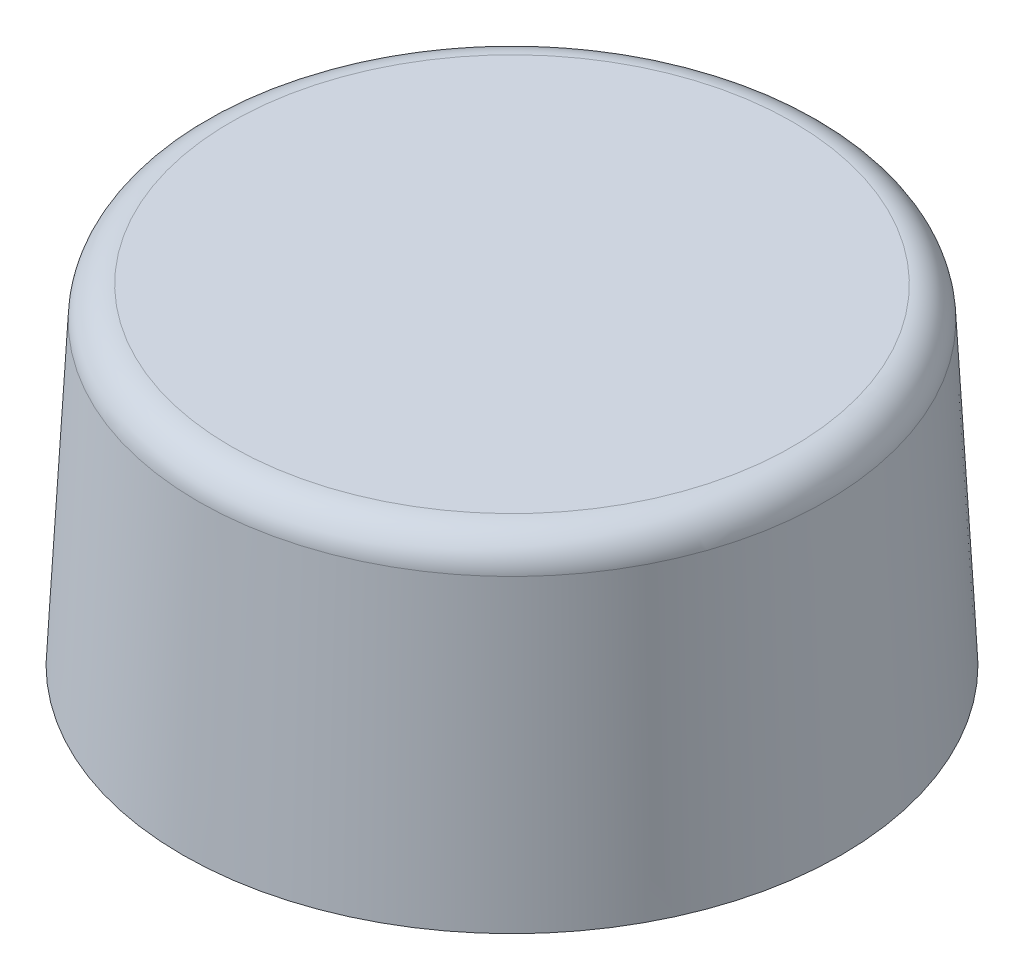
from build123d import *

# Parameters (mm, degrees)
SKETCH1_R           = 10
BOSS_EXTRUDE1_DEPTH = 10
BOSS_EXTRUDE1_TAPER = 3
DOME1_FACE_RADIUS   = 10
DOME1_HEIGHT        = 3
FILLET1_R           = 1


with BuildPart() as part:
    # Sketch1 → Boss-Extrude1 (new body)
    with BuildSketch(Plane(origin=(0, 0, 0), x_dir=(1, 0, 0), z_dir=(0, 1, 0))):
        Circle(SKETCH1_R)
    extrude(amount=BOSS_EXTRUDE1_DEPTH, taper=BOSS_EXTRUDE1_TAPER)

    # Dome1: a dome of height H over a round flat face of radius A is a cap of a sphere of radius (A * A + H * H) / (2 * H)
    dome1_r = (DOME1_FACE_RADIUS * DOME1_FACE_RADIUS + DOME1_HEIGHT * DOME1_HEIGHT) / (2 * DOME1_HEIGHT)
    dome1_base = Plane((0, 0, 0), z_dir=(0, -1, 0))
    with Locations(dome1_base.offset(DOME1_HEIGHT - dome1_r)):
        dome1_ball = Sphere(dome1_r, mode=Mode.PRIVATE)
    add(split(dome1_ball, bisect_by=dome1_base, keep=Keep.TOP, mode=Mode.PRIVATE))

    # Fillet1
    fillet1_edges = [part.edges().sort_by_distance(p)[0] for p in [
        (-9.475922207, 10, 0),
    ]]
    fillet(fillet1_edges, radius=FILLET1_R)


solid = part.part
